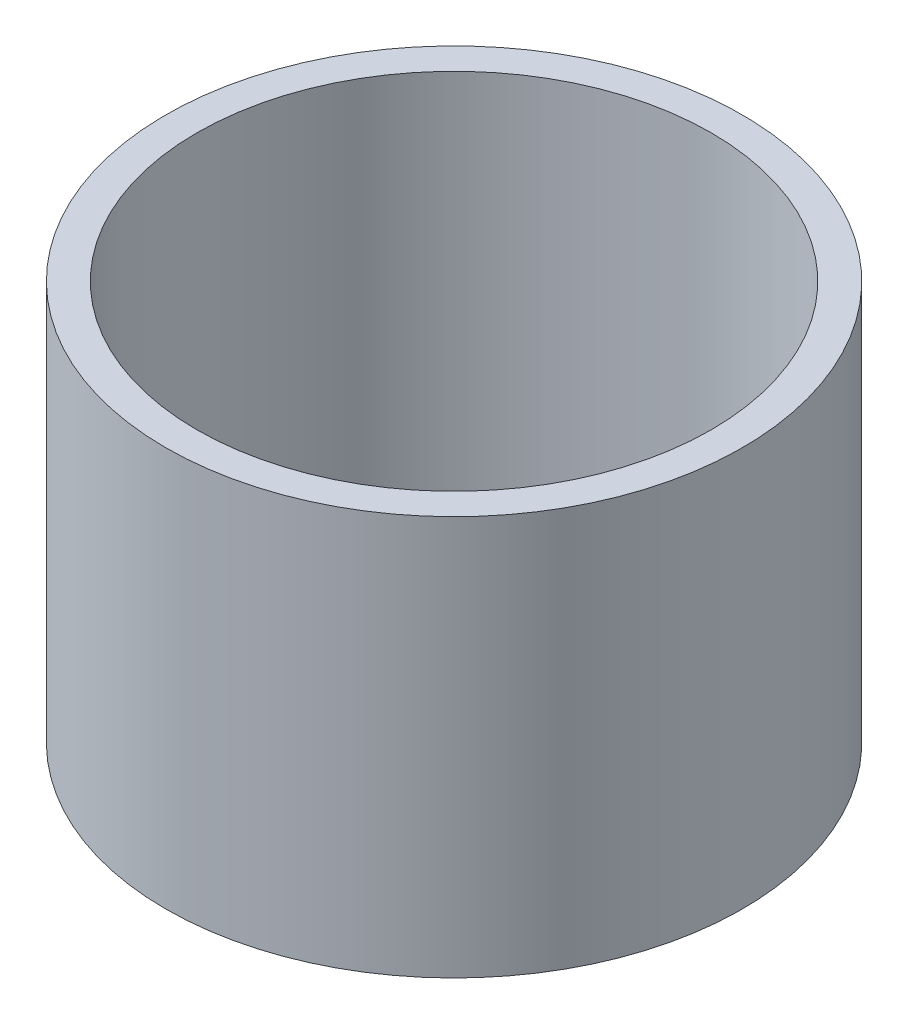
from build123d import *

# Parameters (mm, degrees)
SKETCH1_R           = 31.75
BOSS_EXTRUDE1_DEPTH = 44
G2_TAPPED_HOLE1_D   = 56.656


with BuildPart() as part:
    # Sketch1 → Boss-Extrude1 (new body)
    with BuildSketch(Plane(origin=(0, 0, 0), x_dir=(1, 0, 0), z_dir=(0, 1, 0))):
        Circle(SKETCH1_R)
    extrude(amount=BOSS_EXTRUDE1_DEPTH)

    # G2 Tapped Hole1 (through all)
    with Locations(Plane(origin=(0, 44, 0), x_dir=(1, 0, 0), z_dir=(0, 1, 0))):
        with Locations((0, 0)):
            Hole(G2_TAPPED_HOLE1_D / 2)


solid = part.part
